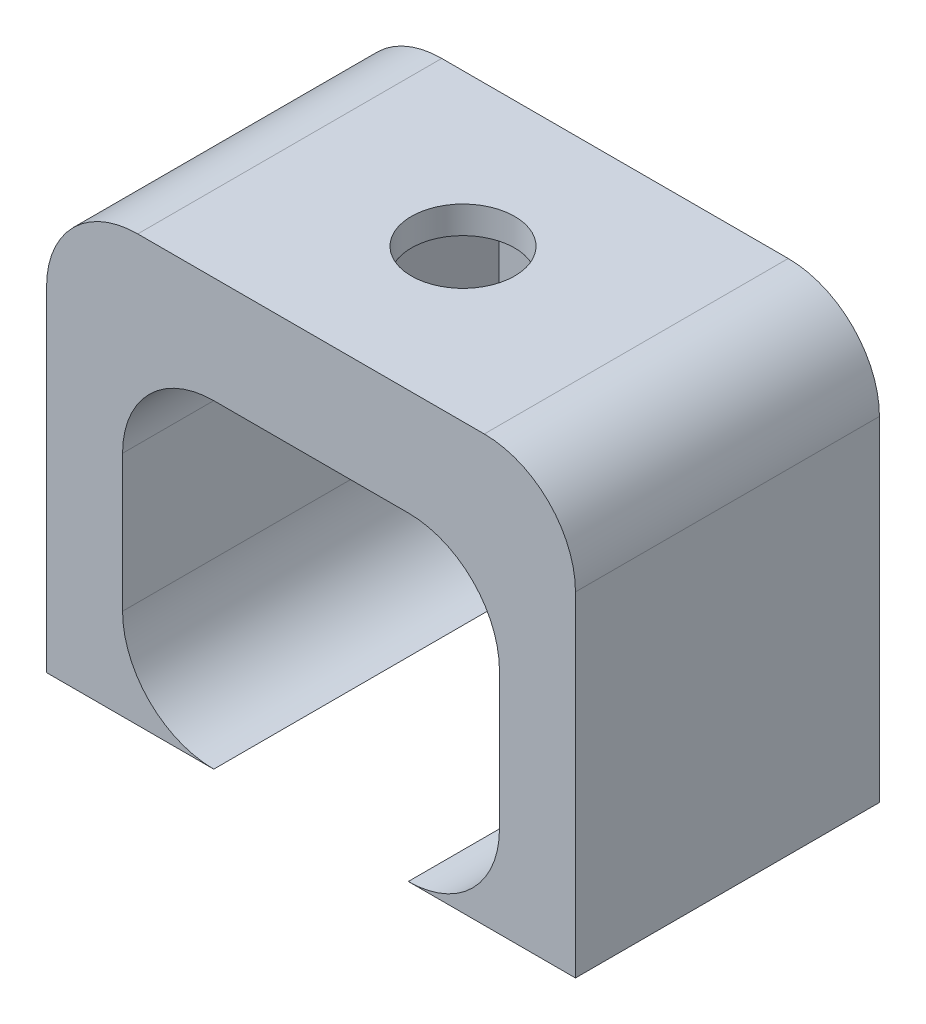
from build123d import *

# Parameters (mm, degrees)
RESSALTO_EXTRUS_O1_DEPTH   = 10
CORTE_EXTRUS_O1_DEPTH      = 2
CORTE_EXTRUS_O1_DEPTH_BACK = 2.6
ESBO_O3_R                  = 1.7
CORTE_EXTRUS_O2_DEPTH      = 1.9
FILETE2_R                  = 3


with BuildPart() as part:
    # Esboço1 → Ressalto-extrusão1 (new body)
    with BuildSketch(Plane.XY):
        with BuildLine():
            Line((3.2, -5.25), (8.7, -5.25))
            Line((8.7, -5.25), (8.7, 8.75))
            Line((8.7, 8.75), (-8.7, 8.75))
            Line((-8.7, 8.75), (-8.7, -5.25))
            Line((-8.7, -5.25), (-3.2, -5.25))
            ThreePointArc((-3.2, -5.25), (-5.321320344, -4.371320344), (-6.2, -2.25))
            Line((-6.2, -2.25), (-6.2, 2.25))
            ThreePointArc((-6.2, 2.25), (-5.321320344, 4.371320344), (-3.2, 5.25))
            Line((-3.2, 5.25), (3.2, 5.25))
            ThreePointArc((3.2, 5.25), (5.321320344, 4.371320344), (6.2, 2.25))
            Line((6.2, 2.25), (6.2, -2.25))
            ThreePointArc((6.2, -2.25), (5.321320344, -4.371320344), (3.2, -5.25))
        make_face()
    extrude(amount=RESSALTO_EXTRUS_O1_DEPTH)

    # Esboço2 → Corte-extrusão1 (cut, two sides)
    with BuildSketch(Plane.XZ.offset(-5.25)) as corte_extrus_o1_sk:
        Polygon((1.616580754, 2.2), (3.233161507, 5), (1.616580754, 7.8), (-1.616580754, 7.8), (-3.233161507, 5), (-1.616580754, 2.2), align=None)
    extrude(amount=CORTE_EXTRUS_O1_DEPTH, mode=Mode.SUBTRACT)
    extrude(corte_extrus_o1_sk.sketch, amount=-CORTE_EXTRUS_O1_DEPTH_BACK, mode=Mode.SUBTRACT)

    # Esboço3 → Corte-extrusão2 (cut, through all)
    with BuildSketch(Plane.XZ.offset(-7.85)):
        with Locations((0, 5)):
            Circle(ESBO_O3_R)
    extrude(amount=-CORTE_EXTRUS_O2_DEPTH, mode=Mode.SUBTRACT)

    # Filete2
    filete2_edges = [part.edges().sort_by_distance(p)[0] for p in [
        (-8.7, 8.75, 5),
        (8.7, 8.75, 5),
    ]]
    fillet(filete2_edges, radius=FILETE2_R)


solid = part.part
